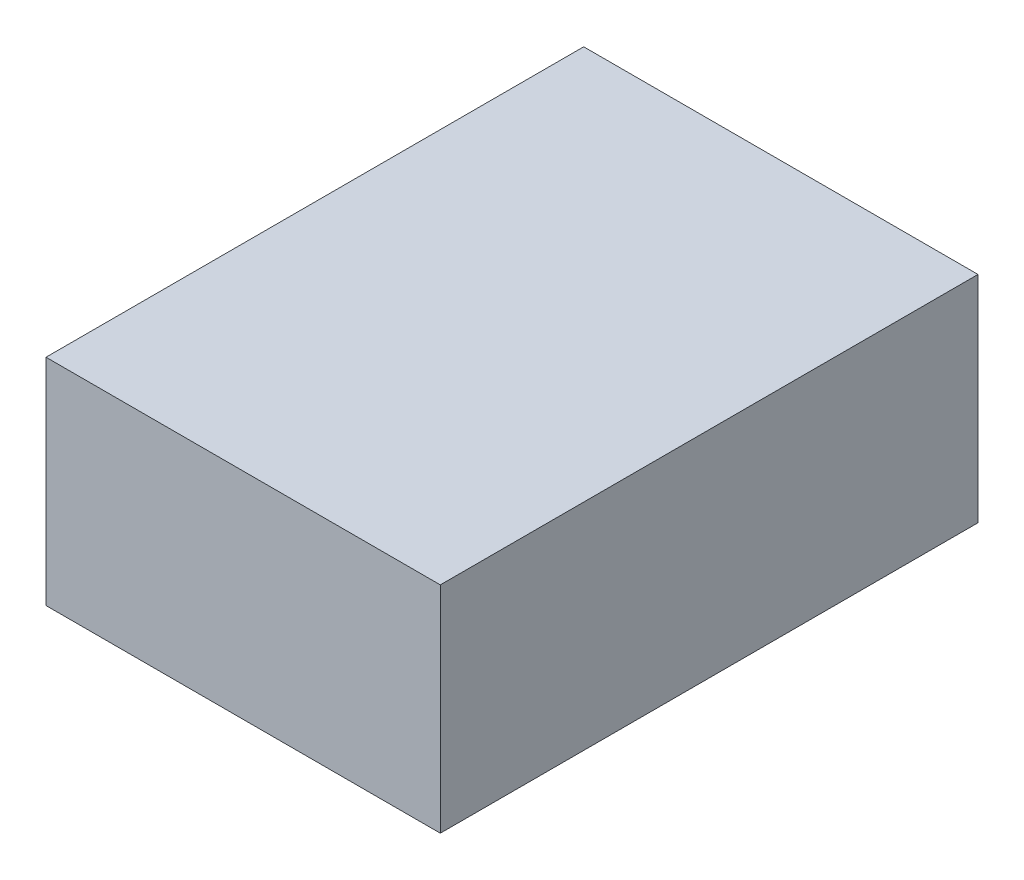
from build123d import *

# Parameters (mm, degrees)
ESQUISSE1_W        = 220
ESQUISSE1_H        = 120
BOSS_EXTRU_1_DEPTH = 300


with BuildPart() as part:
    # Esquisse1 → Boss.-Extru.1 (new body)
    with BuildSketch(Plane.XY):
        with Locations((110, -60)):
            Rectangle(ESQUISSE1_W, ESQUISSE1_H)
    extrude(amount=BOSS_EXTRU_1_DEPTH)


solid = part.part
